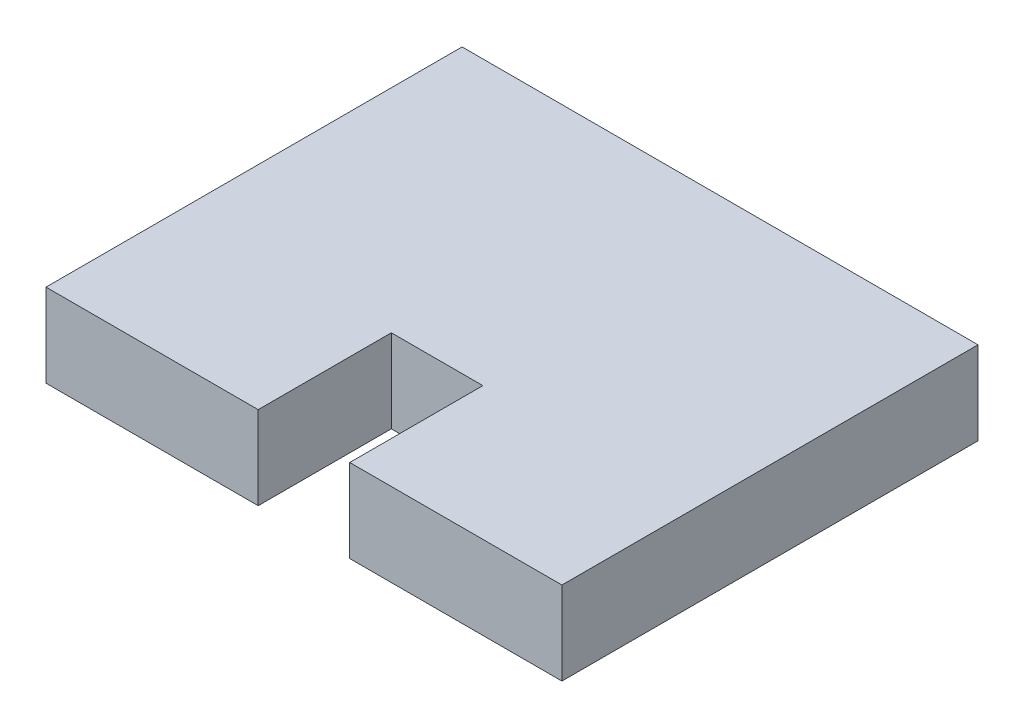
from build123d import *

# Parameters (mm, degrees)
CROQUIS1_W              = 31
CROQUIS1_H              = 25
SALIENTE_EXTRUIR1_DEPTH = 5
CROQUIS2_W              = 5.5
CROQUIS2_H              = 8
CORTAR_EXTRUIR1_DEPTH   = 5


with BuildPart() as part:
    # Croquis1 → Saliente-Extruir1 (new body)
    with BuildSketch(Plane(origin=(0, 0, 0), x_dir=(1, 0, 0), z_dir=(0, 1, 0))):
        Rectangle(CROQUIS1_W, CROQUIS1_H)
    extrude(amount=SALIENTE_EXTRUIR1_DEPTH)

    # Croquis2 → Cortar-Extruir1 (cut)
    with BuildSketch(Plane(origin=(0, 5, 0), x_dir=(1, 0, 0), z_dir=(0, 1, 0))):
        with Locations((0, -8.5)):
            Rectangle(CROQUIS2_W, CROQUIS2_H)
    extrude(amount=-CORTAR_EXTRUIR1_DEPTH, mode=Mode.SUBTRACT)


solid = part.part
